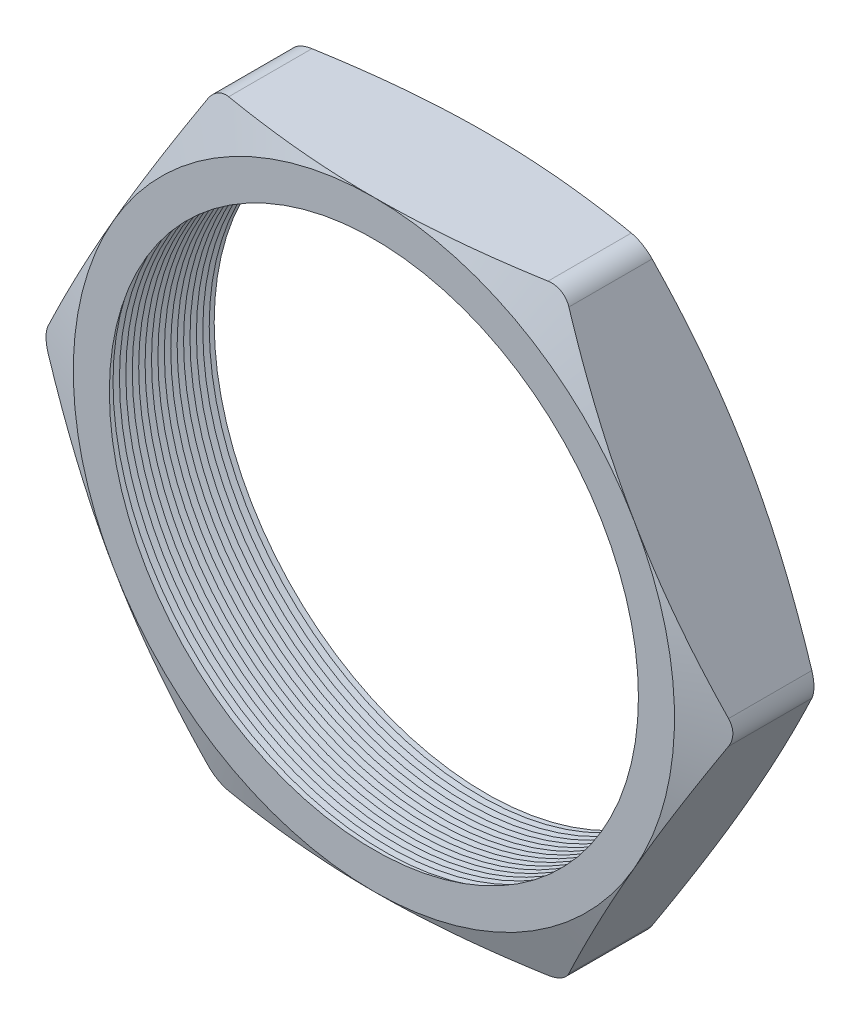
from build123d import *

# Parameters (mm, degrees)
SKETCH1_R          = 8.382
EXTRUDE1_DEPTH     = 3.556
FILLET1_R          = 0.762
SKETCH2_OUTSIDE_W  = 54.624
SKETCH2_OUTSIDE_H  = 51.912
SKETCH2_OUTSIDE_R  = 9.525
CUT_EXTRUDE1_DEPTH = 4.556
CUT_EXTRUDE1_DRAFT = -70
SKETCH3_OUTSIDE_W  = 54.624
SKETCH3_OUTSIDE_H  = 51.912
SKETCH3_OUTSIDE_R  = 9.525
CUT_EXTRUDE2_DEPTH = 4.5560001
CUT_EXTRUDE2_DRAFT = -70
LPATTERN1_COUNT    = 18
LPATTERN1_PITCH    = 0.2032


with BuildPart() as part:
    # Sketch1 → Extrude1 (new body)
    with BuildSketch(Plane.XY):
        Polygon((-10.998522628, 0), (-5.499261314, -9.525), (5.499261314, -9.525), (10.998522628, 0), (5.499261314, 9.525), (-5.499261314, 9.525), align=None)
        Circle(SKETCH1_R, mode=Mode.SUBTRACT)
    extrude(amount=EXTRUDE1_DEPTH)

    # Fillet1
    fillet1_edges = [part.edges().sort_by_distance(p)[0] for p in [
        (10.998522628, 0, 1.778),
        (5.499261314, -9.525, 1.778),
        (-5.499261314, -9.525, 1.778),
        (-10.998522628, 0, 1.778),
        (-5.499261314, 9.525, 1.778),
        (5.499261314, 9.525, 1.778),
    ]]
    fillet(fillet1_edges, radius=FILLET1_R)


with BuildPart() as cut_extrude1_tool:
    # Sketch2 outside → Cut-Extrude1 (with draft: the straight prism first)
    with BuildSketch(Plane.XY.offset(3.556)):
        Rectangle(SKETCH2_OUTSIDE_W, SKETCH2_OUTSIDE_H)
        Circle(SKETCH2_OUTSIDE_R, mode=Mode.SUBTRACT)
    extrude(amount=-CUT_EXTRUDE1_DEPTH)
    # Cut-Extrude1: the draft: its side faces are tilted about the plane it starts from
    cut_extrude1_sides = [cut_extrude1_tool.faces().sort_by_distance(p)[0] for p in [
        (0, -25.956, 1.278),
        (27.312, 0, 1.278),
        (0, 25.956, 1.278),
        (-27.312, 0, 1.278),
        (-9.525, 0, 1.278),
    ]]
    draft(cut_extrude1_sides, Plane.XY.offset(3.556), CUT_EXTRUDE1_DRAFT)


with BuildPart() as part_1:
    add(part.part)

    # Cut-Extrude1: cut by cut_extrude1_tool
    add(cut_extrude1_tool.part, mode=Mode.SUBTRACT)


with BuildPart() as cut_extrude2_tool:
    # Sketch3 outside → Cut-Extrude2 (with draft: the straight prism first)
    with BuildSketch(Plane(origin=(0, 0, 0), x_dir=(-1, 0, 0), z_dir=(0, 0, -1))):
        Rectangle(SKETCH3_OUTSIDE_W, SKETCH3_OUTSIDE_H)
        Circle(SKETCH3_OUTSIDE_R, mode=Mode.SUBTRACT)
    extrude(amount=-CUT_EXTRUDE2_DEPTH)
    # Cut-Extrude2: the draft: its side faces are tilted about the plane it starts from
    cut_extrude2_sides = [cut_extrude2_tool.faces().sort_by_distance(p)[0] for p in [
        (0, -25.956, 2.27800005),
        (-27.312, 0, 2.27800005),
        (0, 25.956, 2.27800005),
        (27.312, 0, 2.27800005),
        (9.525, 0, 2.27800005),
    ]]
    draft(cut_extrude2_sides, Plane(origin=(0, 0, 0), x_dir=(-1, 0, 0), z_dir=(0, 0, -1)), CUT_EXTRUDE2_DRAFT)


with BuildPart() as part_2:
    add(part_1.part)

    # Cut-Extrude2: cut by cut_extrude2_tool
    add(cut_extrude2_tool.part, mode=Mode.SUBTRACT)

    # Sketch4 → Cut-Revolve1 (revolve, cut)
    with BuildSketch(Plane(origin=(0, 0, 0), x_dir=(1, 0, 0), z_dir=(0, 1, 0))):
        Polygon((-8.382, -3.556), (-8.382, -3.116059095), (-8.763, -3.336029547), align=None)
    cut_revolve1 = revolve(axis=Axis((0, 0, 3.556), (0, 0, -1)), mode=Mode.SUBTRACT)

    # LPattern1: Cut-Revolve1 ×18
    with Locations(*[(0, 0, -i * LPATTERN1_PITCH) for i in range(1, LPATTERN1_COUNT)]):
        add(cut_revolve1, mode=Mode.SUBTRACT)


solid = part_2.part
